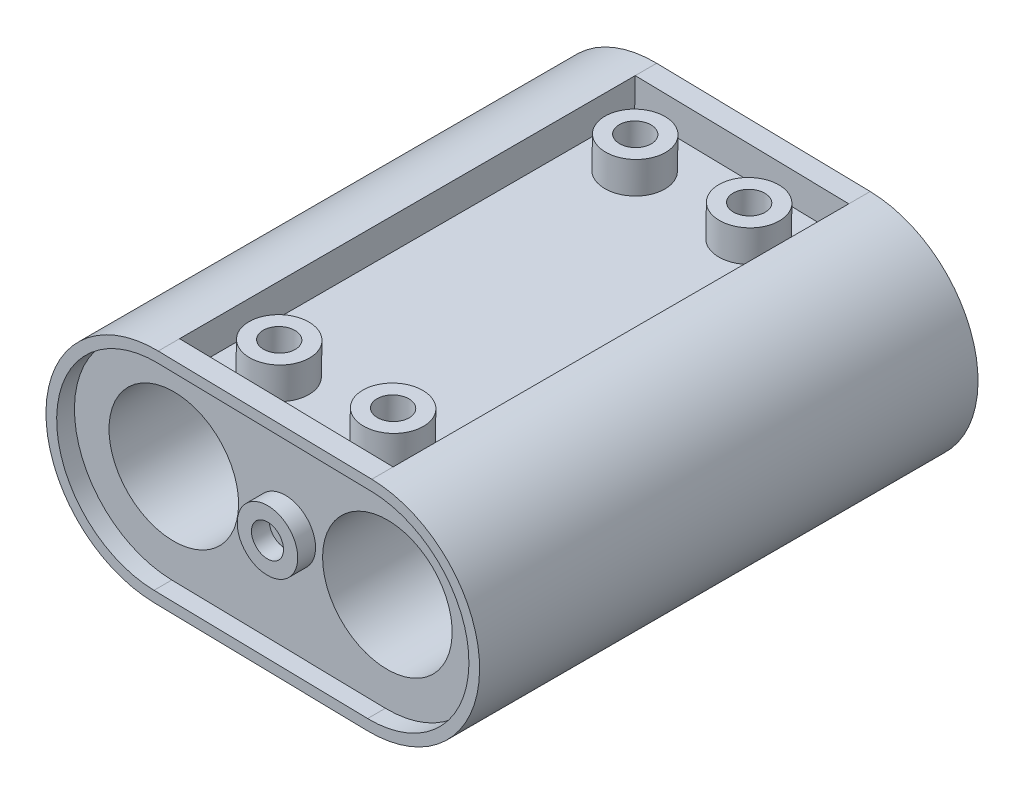
from build123d import *

# Parameters (mm, degrees)
SKETCH_1_R          = 9.1
EXTRUDE_1_DEPTH     = 65
EXTRUDE_2_DEPTH     = 2.5
EXTRUDE_3_DEPTH     = 2.5
SKETCH_7_W          = 30
SKETCH_7_H          = 64
CUT_EXTRUDE_4_DEPTH = 4.5
SKETCH_8_W          = 30
SKETCH_8_H          = 64
CUT_EXTRUDE_5_DEPTH = 4.5
SKETCH_4_R          = 4.159545235
SKETCH_4_R_2        = 2.25
EXTRUDE_4_DEPTH     = 2.5
SKETCH_10_R         = 2.25
CUT_EXTRUDE_6_DEPTH = 2.5
SKETCH_11_R         = 4.25
SKETCH_11_R_2       = 2.25
EXTRUDE_5_DEPTH     = 4.5
SKETCH_3_R          = 4.25
SKETCH_3_R_2        = 2.25
EXTRUDE_6_DEPTH     = 2.5


with BuildPart() as part:
    # Эскиз1 → Бобышка-Вытянуть1 (new body)
    with BuildSketch(Plane.XY):
        with BuildLine():
            Line((-15.348477888, 15.359663741), (14.645527362, 14.759956259))
            ThreePointArc((14.645527362, 14.759956259), (29.785323334, -0.997609119), (14.027757956, -16.137405091))
            Line((14.027757956, -16.137405091), (-15.966247294, -15.537697609))
            ThreePointArc((-15.966247294, -15.537697609), (-31.106043266, 0.219867769), (-15.348477888, 15.359663741))
        make_face()
        with Locations((-15.657362591, -0.089016934)):
            Circle(SKETCH_1_R, mode=Mode.SUBTRACT)
        with Locations((14.336642659, -0.688724416)):
            Circle(SKETCH_1_R, mode=Mode.SUBTRACT)
    extrude(amount=EXTRUDE_1_DEPTH)

    # Эскиз2 → Бобышка-Вытянуть2 (add)
    with BuildSketch(Plane.XY.offset(65)):
        with BuildLine():
            Line((-15.966247294, -15.537697609), (14.027757956, -16.137405091))
            ThreePointArc((14.027757956, -16.137405091), (29.785323334, -0.997609119), (14.645527362, 14.759956259))
            Line((14.645527362, 14.759956259), (-15.348477888, 15.359663741))
            ThreePointArc((-15.348477888, 15.359663741), (-31.106043266, 0.219867769), (-15.966247294, -15.537697609))
        make_face()
        with BuildLine():
            Line((-15.378463262, 13.859963479), (14.615541988, 13.260255996))
            ThreePointArc((14.615541988, 13.260255996), (28.285623072, -0.967623745), (14.05774333, -14.637704829))
            Line((14.05774333, -14.637704829), (-15.93626192, -14.037997346))
            ThreePointArc((-15.93626192, -14.037997346), (-29.606343003, 0.189882395), (-15.378463262, 13.859963479))
        make_face(mode=Mode.SUBTRACT)
    extrude(amount=EXTRUDE_2_DEPTH)

    # Эскиз5 → Бобышка-Вытянуть3 (add)
    with BuildSketch(Plane(origin=(0, 0, 0), x_dir=(-1, 0, 0), z_dir=(0, 0, -1))):
        with BuildLine():
            Line((15.966247294, -15.537697609), (-14.027757956, -16.137405091))
            ThreePointArc((-14.027757956, -16.137405091), (-29.785323334, -0.997609119), (-14.645527362, 14.759956259))
            Line((-14.645527362, 14.759956259), (15.348477888, 15.359663741))
            ThreePointArc((15.348477888, 15.359663741), (31.106043266, 0.219867769), (15.966247294, -15.537697609))
        make_face()
        with BuildLine():
            Line((-14.615541988, 13.260255996), (15.378463262, 13.859963479))
            ThreePointArc((15.378463262, 13.859963479), (29.606343003, 0.189882395), (15.93626192, -14.037997346))
            Line((15.93626192, -14.037997346), (-14.05774333, -14.637704829))
            ThreePointArc((-14.05774333, -14.637704829), (-28.285623072, -0.967623745), (-14.615541988, 13.260255996))
        make_face(mode=Mode.SUBTRACT)
    extrude(amount=EXTRUDE_3_DEPTH)

    # Эскиз7 → Вырез-Вытянуть4 (cut)
    with BuildSketch(Plane(origin=(0.300848748, 15.046767274, 0), x_dir=(0.999800175, -0.019990249, 0), z_dir=(0.019990249, 0.999800175, 0))):
        with Locations((-0.652454388, -32.5)):
            Rectangle(SKETCH_7_W, SKETCH_7_H)
    extrude(amount=-CUT_EXTRUDE_4_DEPTH, mode=Mode.SUBTRACT)

    # Эскиз8 → Вырез-Вытянуть5 (cut)
    with BuildSketch(Plane(origin=(-0.316920658, -15.850594076, 0), x_dir=(-0.999800175, 0.019990249, 0), z_dir=(-0.019990249, -0.999800175, 0))):
        with Locations((0.652454388, -32.5)):
            Rectangle(SKETCH_8_W, SKETCH_8_H)
    extrude(amount=-CUT_EXTRUDE_5_DEPTH, mode=Mode.SUBTRACT)

    # Эскиз4 → Бобышка-Вытянуть4 (add)
    with BuildSketch(Plane(origin=(0, 0, 0), x_dir=(-1, 0, 0), z_dir=(0, 0, -1))):
        Circle(SKETCH_4_R)
        Circle(SKETCH_4_R_2, mode=Mode.SUBTRACT)
    extrude(amount=EXTRUDE_4_DEPTH)

    # Эскиз10 → Вырез-Вытянуть6 (cut)
    with BuildSketch(Plane(origin=(0, 0, 0), x_dir=(-1, 0, 0), z_dir=(0, 0, -1))):
        Circle(SKETCH_10_R)
    extrude(amount=-CUT_EXTRUDE_6_DEPTH, mode=Mode.SUBTRACT)

    # Эскиз11 → Бобышка-Вытянуть5 (add)
    with BuildSketch(Plane(origin=(0.210892625, 10.547666486, 0), x_dir=(0.999800175, -0.019990249, 0), z_dir=(0.019990249, 0.999800175, 0))):
        with Locations((7.347545612, -7.5)):
            Circle(SKETCH_11_R)
        with Locations((7.347545612, -7.5)):
            Circle(SKETCH_11_R_2, mode=Mode.SUBTRACT)
        with Locations((-8.652454388, -7.5)):
            Circle(SKETCH_11_R)
        with Locations((-8.652454388, -7.5)):
            Circle(SKETCH_11_R_2, mode=Mode.SUBTRACT)
        with Locations((7.347545612, -57.5)):
            Circle(SKETCH_11_R)
        with Locations((7.347545612, -57.5)):
            Circle(SKETCH_11_R_2, mode=Mode.SUBTRACT)
        with Locations((-8.652454388, -57.5)):
            Circle(SKETCH_11_R)
        with Locations((-8.652454388, -57.5)):
            Circle(SKETCH_11_R_2, mode=Mode.SUBTRACT)
    extrude(amount=EXTRUDE_5_DEPTH)

    # Эскиз3 → Бобышка-Вытянуть6 (add)
    with BuildSketch(Plane.XY.offset(65)):
        Circle(SKETCH_3_R)
        Circle(SKETCH_3_R_2, mode=Mode.SUBTRACT)
    extrude(amount=EXTRUDE_6_DEPTH)


solid = part.part
